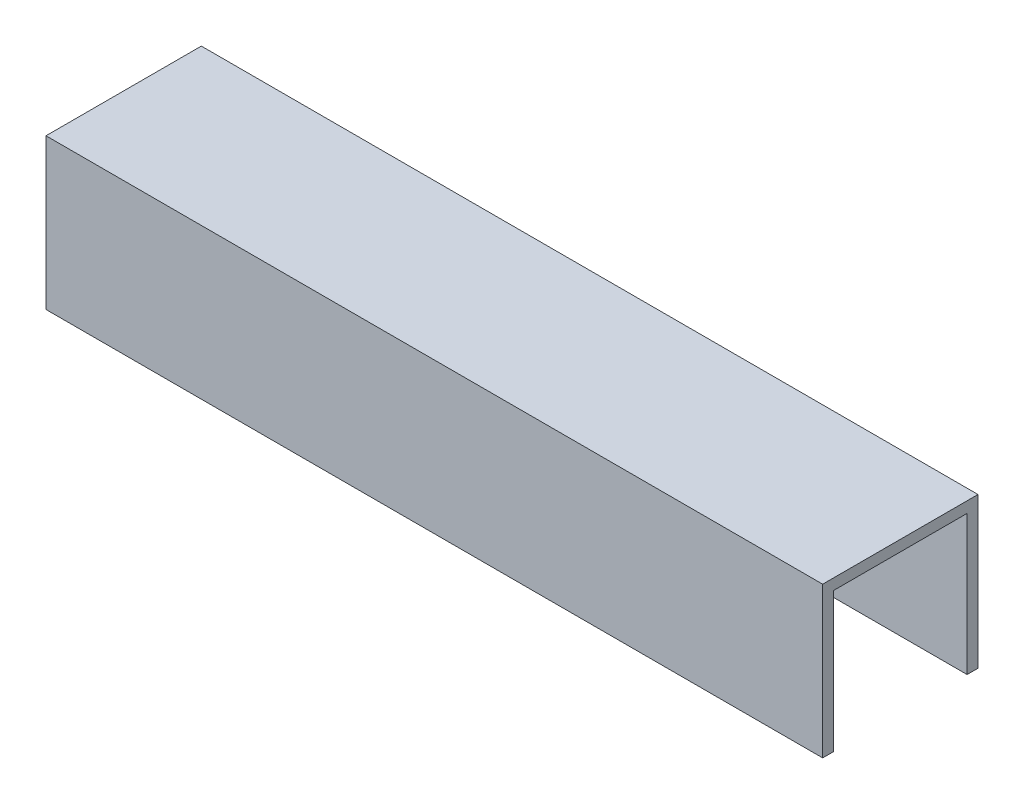
from build123d import *

# Parameters (mm, degrees)
BOSS_EXTRUDE1_DEPTH = 160


with BuildPart() as part:
    # Sketch1 → Boss-Extrude1 (new body)
    with BuildSketch(Plane(origin=(80, 0, 0), x_dir=(0, 0, -1), z_dir=(1, 0, 0))):
        Polygon((-13.75, 0), (-13.75, 28.75), (13.75, 28.75), (13.75, 0), (16, 0), (16, 31), (-16, 31), (-16, 0), align=None)
    extrude(amount=-BOSS_EXTRUDE1_DEPTH)


solid = part.part
